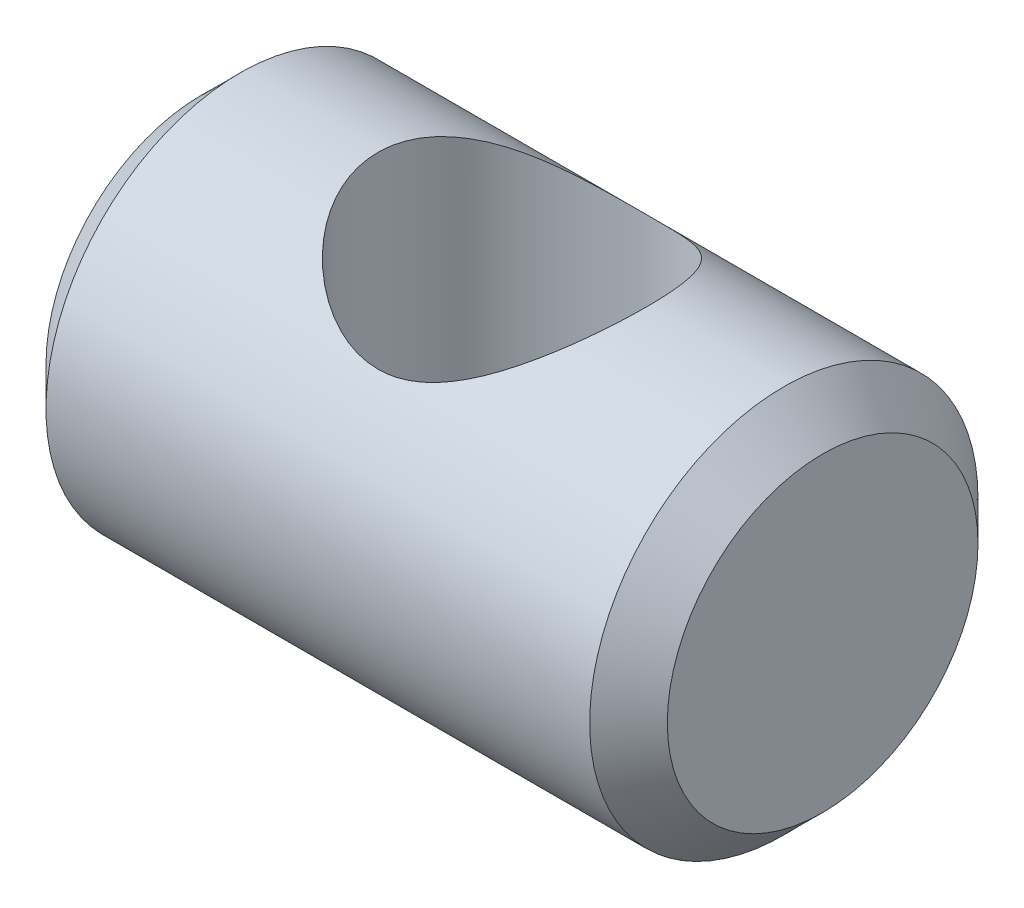
from build123d import *

# Parameters (mm, degrees)
SKETCH1_R               = 5
BOSS_EXTRUDE1_DEPTH     = 16
SKETCH2_R               = 3.453172081
CUT_EXTRUDE1_DEPTH      = 6
CUT_EXTRUDE1_DEPTH_BACK = 6
CHAMFER1_SIZE           = 1


with BuildPart() as part:
    # Sketch1 → Boss-Extrude1 (new body)
    with BuildSketch(Plane(origin=(0, 0, 0), x_dir=(0, 0, -1), z_dir=(1, 0, 0))):
        Circle(SKETCH1_R)
    extrude(amount=BOSS_EXTRUDE1_DEPTH)

    # Sketch2 → Cut-Extrude1 (cut, two sides)
    with BuildSketch(Plane(origin=(0, 0, 0), x_dir=(1, 0, 0), z_dir=(0, 1, 0))) as cut_extrude1_sk:
        with Locations((8, 0)):
            Circle(SKETCH2_R)
    extrude(amount=CUT_EXTRUDE1_DEPTH, mode=Mode.SUBTRACT)
    extrude(cut_extrude1_sk.sketch, amount=-CUT_EXTRUDE1_DEPTH_BACK, mode=Mode.SUBTRACT)

    # Chamfer1
    chamfer1_edges = [part.edges().sort_by_distance(p)[0] for p in [
        (0, 0, 5),
        (16, 0, 5),
    ]]
    chamfer(chamfer1_edges, length=CHAMFER1_SIZE)


solid = part.part
